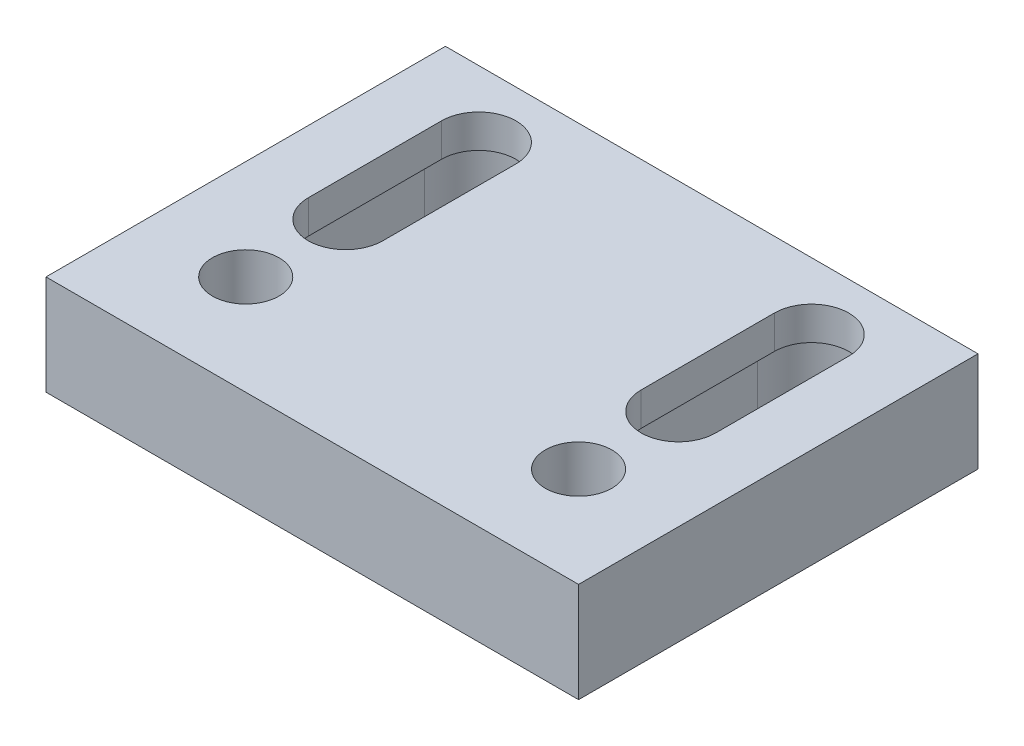
from build123d import *

# Parameters (mm, degrees)
SKETCH1_W               = 114.3
SKETCH1_H               = 76.2
BASE_EXTRUDE_DEPTH      = 19.05
F_1_2_20_TAPPED_HOLE1_D = 12.7
CUT_EXTRUDE1_DEPTH      = 12.7
CUT_EXTRUDE2_DEPTH      = 12.7
SKETCH7_W               = 6.35
SKETCH7_H               = 76.2
CUT_EXTRUDE3_DEPTH      = 1
CUT_EXTRUDE3_DEPTH_BACK = 20.05
SKETCH8_W               = 6.35
SKETCH8_H               = 76.2
CUT_EXTRUDE4_DEPTH      = 1
CUT_EXTRUDE4_DEPTH_BACK = 20.05


with BuildPart() as part:
    # Sketch1 → Base-Extrude (new body)
    with BuildSketch(Plane(origin=(0, 0, 0), x_dir=(1, 0, 0), z_dir=(0, 1, 0))):
        with Locations((57.15, 38.1)):
            Rectangle(SKETCH1_W, SKETCH1_H)
        with BuildLine():
            Line((96.012, 63.5), (96.012, 38.1))
            ThreePointArc((96.012, 38.1), (88.9, 30.988), (81.788, 38.1))
            Line((81.788, 38.1), (81.788, 63.5))
            ThreePointArc((81.788, 63.5), (88.9, 70.612), (96.012, 63.5))
        make_face(mode=Mode.SUBTRACT)
        with BuildLine():
            Line((18.288, 63.5), (18.288, 38.1))
            ThreePointArc((18.288, 38.1), (25.4, 30.988), (32.512, 38.1))
            Line((32.512, 38.1), (32.512, 63.5))
            ThreePointArc((32.512, 63.5), (25.4, 70.612), (18.288, 63.5))
        make_face(mode=Mode.SUBTRACT)
    extrude(amount=BASE_EXTRUDE_DEPTH)

    # 1/2-20 Tapped Hole1 (through all)
    with Locations(Plane(origin=(0, 19.05, 0), x_dir=(-1, 0, 0), z_dir=(0, 1, 0))):
        with Locations((-25.4, -19.05), (-88.9, -19.05)):
            Hole(F_1_2_20_TAPPED_HOLE1_D / 2)

    # Sketch4 → Cut-Extrude1 (cut)
    with BuildSketch(Plane.XZ):
        with BuildLine():
            Line((15.0749, -63.5), (15.0749, -38.1))
            ThreePointArc((15.0749, -38.1), (25.4, -27.7749), (35.7251, -38.1))
            Line((35.7251, -38.1), (35.7251, -63.5))
            ThreePointArc((35.7251, -63.5), (25.4, -73.8251), (15.0749, -63.5))
        make_face()
    extrude(amount=-CUT_EXTRUDE1_DEPTH, mode=Mode.SUBTRACT)

    # Sketch5 → Cut-Extrude2 (cut)
    with BuildSketch(Plane.XZ):
        with BuildLine():
            Line((99.2251, -38.1), (99.2251, -63.5))
            ThreePointArc((99.2251, -63.5), (88.9, -73.8251), (78.5749, -63.5))
            Line((78.5749, -63.5), (78.5749, -38.1))
            ThreePointArc((78.5749, -38.1), (88.9, -27.7749), (99.2251, -38.1))
        make_face()
    extrude(amount=-CUT_EXTRUDE2_DEPTH, mode=Mode.SUBTRACT)

    # Sketch7 → Cut-Extrude3 (cut, two sides)
    with BuildSketch(Plane.XZ) as cut_extrude3_sk:
        with Locations((111.125, -38.1)):
            Rectangle(SKETCH7_W, SKETCH7_H)
    extrude(amount=CUT_EXTRUDE3_DEPTH, mode=Mode.SUBTRACT)
    extrude(cut_extrude3_sk.sketch, amount=-CUT_EXTRUDE3_DEPTH_BACK, mode=Mode.SUBTRACT)

    # Sketch8 → Cut-Extrude4 (cut, two sides)
    with BuildSketch(Plane.XZ) as cut_extrude4_sk:
        with Locations((3.175, -38.1)):
            Rectangle(SKETCH8_W, SKETCH8_H)
    extrude(amount=CUT_EXTRUDE4_DEPTH, mode=Mode.SUBTRACT)
    extrude(cut_extrude4_sk.sketch, amount=-CUT_EXTRUDE4_DEPTH_BACK, mode=Mode.SUBTRACT)


solid = part.part
